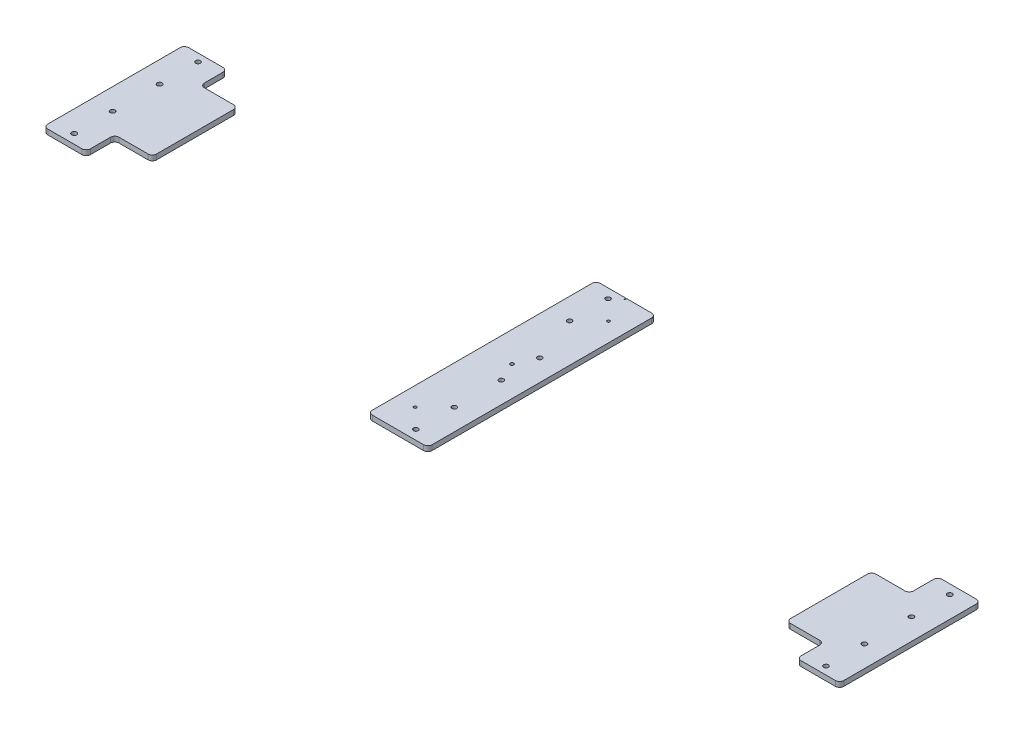
from build123d import *

# Parameters (mm, degrees)
SKETCH3_R             = 1.65
SKETCH3_R_2           = 2.750000008
SKETCH3_R_3           = 2.75000001
SKETCH3_R_4           = 2.750000011
SKETCH3_R_5           = 2
SKETCH3_R_6           = 1.650000009
BOSS_EXTRUDE1_DEPTH   = 6
SKETCH3_R_7           = 2.737785329
SKETCH3_R_8           = 2.827370138
SKETCH3_R_9           = 2.782612344
SKETCH3_R_10          = 2.88528129
BOSS_EXTRUDE1_2_DEPTH = 6
BOSS_EXTRUDE1_3_DEPTH = 6
FILLET1_R             = 5
FILLET2_R             = 5
FILLET3_R             = 5


with BuildPart() as part:
    # Sketch3 → Boss-Extrude1 (new body)
    with BuildSketch(Plane(origin=(0, -250.102226831, 0), x_dir=(-1, 0, 0), z_dir=(0, 1, 0))):
        Polygon((34.97959429, 48.637879031), (34.97959429, 315.637879023), (-34.989357732, 315.637879023), (-34.989357732, 48.637879031), (-1.247447862, 48.637879031), (-0.004881721, 52.137879031), (-0.004881721, 48.637879031), align=None)
        with Locations((-13.004881721, 82.137879031)):
            Circle(SKETCH3_R, mode=Mode.SUBTRACT)
        with Locations((-10.004881721, 159.637879023)):
            Circle(SKETCH3_R_2, mode=Mode.SUBTRACT)
        with Locations((-10.004881721, 204.637879023)):
            Circle(SKETCH3_R_2, mode=Mode.SUBTRACT)
        with Locations((-10.004881721, 259.637879023)):
            Circle(SKETCH3_R_3, mode=Mode.SUBTRACT)
        with Locations((-10.004881721, 304.637879023)):
            Circle(SKETCH3_R_4, mode=Mode.SUBTRACT)
        with Locations((9.995118279, 59.637879031)):
            Circle(SKETCH3_R_2, mode=Mode.SUBTRACT)
        with Locations((9.995118279, 104.637879031)):
            Circle(SKETCH3_R_2, mode=Mode.SUBTRACT)
        with Locations((-0.006935953, 182.137879031)):
            Circle(SKETCH3_R_5, mode=Mode.SUBTRACT)
        with Locations((12.995118279, 282.544201287)):
            Circle(SKETCH3_R_6, mode=Mode.SUBTRACT)
    extrude(amount=BOSS_EXTRUDE1_DEPTH)

    # Fillet3
    fillet3_edges = [part.edges().sort_by_distance(p)[0] for p in [
        (-34.97959429, -247.102226831, 48.637879031),
        (-34.97959429, -247.102226831, 315.637879023),
        (34.989357732, -247.102226831, 315.637879023),
        (34.989357732, -247.102226831, 48.637879031),
    ]]
    fillet(fillet3_edges, radius=FILLET3_R)


with BuildPart() as body_2:
    # Sketch3 → Boss-Extrude1 2 (new body)
    with BuildSketch(Plane(origin=(0, -250.102226831, 0), x_dir=(-1, 0, 0), z_dir=(0, 1, 0))):
        Polygon((514.995118279, 50.547010025), (514.995118279, 215.547012772), (464.995118279, 215.556136576), (464.995118279, 182.137879031), (420.995118279, 182.137879031), (420.995118279, 82.137879031), (464.995118279, 82.137879031), (464.995118279, 50.556133829), align=None)
        with Locations((489.995118279, 59.637879031)):
            Circle(SKETCH3_R_7, mode=Mode.SUBTRACT)
        with Locations((489.995118279, 104.637879031)):
            Circle(SKETCH3_R_8, mode=Mode.SUBTRACT)
        with Locations((489.995118279, 159.667500187)):
            Circle(SKETCH3_R_9, mode=Mode.SUBTRACT)
        with Locations((489.995118279, 204.608257859)):
            Circle(SKETCH3_R_10, mode=Mode.SUBTRACT)
    extrude(amount=BOSS_EXTRUDE1_2_DEPTH)

    # Fillet1
    fillet1_edges = [body_2.edges().sort_by_distance(p)[0] for p in [
        (-514.995118279, -247.102226831, 50.547010025),
        (-464.995118279, -247.102226831, 50.556133829),
        (-464.995118279, -247.102226831, 215.556136576),
        (-514.995118279, -247.102226831, 215.547012772),
        (-464.995118279, -247.102226831, 82.137879031),
        (-420.995118279, -247.102226831, 82.137879031),
        (-420.995118279, -247.102226831, 182.137879031),
        (-464.995118279, -247.102226831, 182.137879031),
    ]]
    fillet(fillet1_edges, radius=FILLET1_R)


with BuildPart() as body_3:
    # Sketch3 → Boss-Extrude1 3 (new body)
    with BuildSketch(Plane(origin=(0, -250.102226831, 0), x_dir=(-1, 0, 0), z_dir=(0, 1, 0))):
        Polygon((-515.032993798, 313.634770287), (-515.002885243, 148.634770287), (-465.002884411, 148.634770287), (-465.008982444, 182.053027276), (-421.008983176, 182.061056224), (-421.027230785, 282.061054559), (-465.027230052, 282.053025611), (-465.032992966, 313.634770287), align=None)
        with Locations((-490.004881721, 159.57808692)):
            Circle(SKETCH3_R_10, mode=Mode.SUBTRACT)
        with Locations((-490.013082334, 204.518843844)):
            Circle(SKETCH3_R_9, mode=Mode.SUBTRACT)
        with Locations((-490.023123924, 259.548464084)):
            Circle(SKETCH3_R_8, mode=Mode.SUBTRACT)
        with Locations((-490.031335348, 304.548463334)):
            Circle(SKETCH3_R_7, mode=Mode.SUBTRACT)
    extrude(amount=BOSS_EXTRUDE1_3_DEPTH)

    # Fillet2
    fillet2_edges = [body_3.edges().sort_by_distance(p)[0] for p in [
        (421.008983176, -247.102226831, 182.061056224),
        (421.027230785, -247.102226831, 282.061054559),
        (465.027230052, -247.102226831, 282.053025611),
        (465.008982444, -247.102226831, 182.053027276),
        (465.002884411, -247.102226831, 148.634770287),
        (515.002885243, -247.102226831, 148.634770287),
        (465.032992966, -247.102226831, 313.634770287),
        (515.032993798, -247.102226831, 313.634770287),
    ]]
    fillet(fillet2_edges, radius=FILLET2_R)


solid = Compound([part.part, body_2.part, body_3.part])
